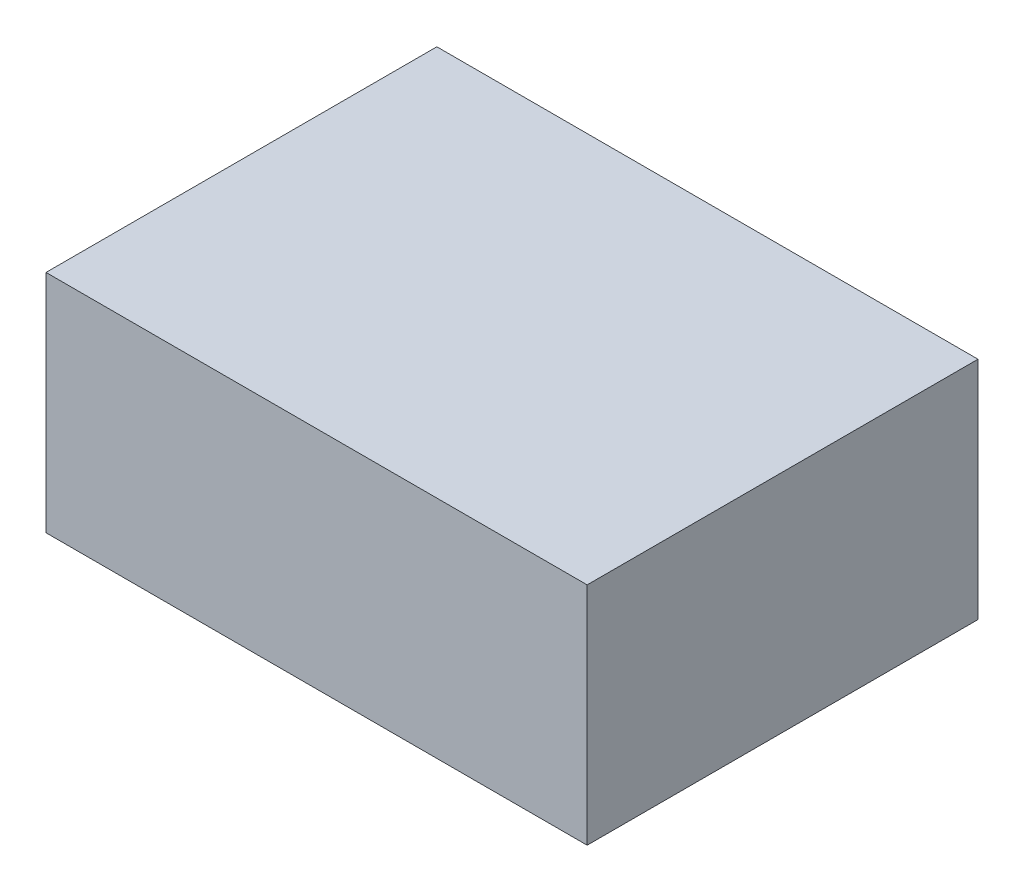
from build123d import *

# Parameters (mm, degrees)
SKETCH1_W           = 45.72
SKETCH1_H           = 33.02
BOSS_EXTRUDE1_DEPTH = 19.05


with BuildPart() as part:
    # Sketch1 → Boss-Extrude1 (new body)
    with BuildSketch(Plane(origin=(0, 0, 0), x_dir=(1, 0, 0), z_dir=(0, 1, 0))):
        Rectangle(SKETCH1_W, SKETCH1_H)
    extrude(amount=BOSS_EXTRUDE1_DEPTH)


solid = part.part
